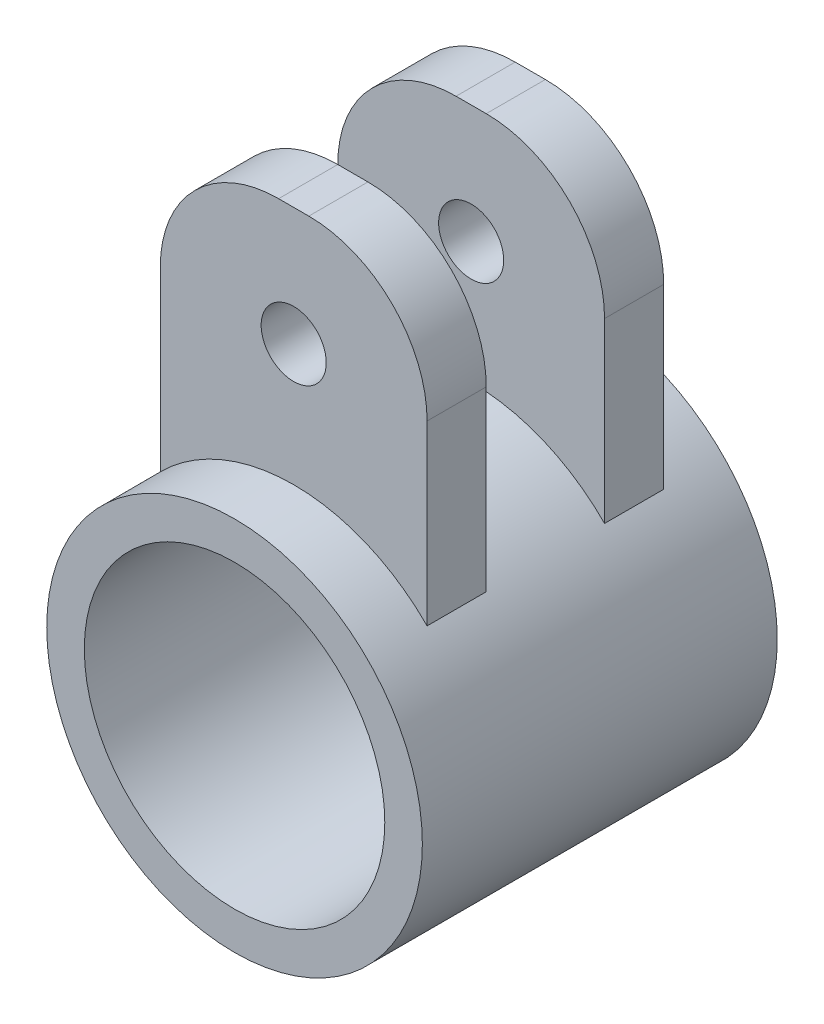
from build123d import *

# Parameters (mm, degrees)
SKETCH1_R            = 15.875
SKETCH1_R_2          = 12.7
BOSS_EXTRUDE1_DEPTH  = 15
BOSS_EXTRUDE2_DEPTH  = 10
CUT_EXTRUDE1_DEPTH   = 5
M5_CLEARANCE_HOLE1_D = 5.5


with BuildPart() as part:
    # Sketch1 → Boss-Extrude1 (new, symmetric)
    with BuildSketch(Plane.XY):
        Circle(SKETCH1_R)
        Circle(SKETCH1_R_2, mode=Mode.SUBTRACT)
    extrude(amount=BOSS_EXTRUDE1_DEPTH, both=True)

    # Sketch3 → Boss-Extrude2 (add, symmetric)
    with BuildSketch(Plane.XY):
        with BuildLine():
            Line((-11.276400848, 11.174005948), (-11.276400848, 26.174005948))
            ThreePointArc((-11.276400848, 26.174005948), (-8.34746866, 33.245073759), (-1.276400848, 36.174005948))
            Line((-1.276400848, 36.174005948), (1.276400848, 36.174005948))
            ThreePointArc((1.276400848, 36.174005948), (8.34746866, 33.245073759), (11.276400848, 26.174005948))
            Line((11.276400848, 26.174005948), (11.276400848, 11.174005948))
            ThreePointArc((11.276400848, 11.174005948), (0, 15.875), (-11.276400848, 11.174005948))
        make_face()
    extrude(amount=BOSS_EXTRUDE2_DEPTH, both=True)

    # Sketch3_2 → Cut-Extrude1 (cut, symmetric)
    with BuildSketch(Plane.XY):
        with BuildLine():
            Line((-11.276400848, 11.174005948), (-11.276400848, 26.174005948))
            ThreePointArc((-11.276400848, 26.174005948), (-8.34746866, 33.245073759), (-1.276400848, 36.174005948))
            Line((-1.276400848, 36.174005948), (1.276400848, 36.174005948))
            ThreePointArc((1.276400848, 36.174005948), (8.34746866, 33.245073759), (11.276400848, 26.174005948))
            Line((11.276400848, 26.174005948), (11.276400848, 11.174005948))
            ThreePointArc((11.276400848, 11.174005948), (0, 15.875), (-11.276400848, 11.174005948))
        make_face()
    extrude(amount=CUT_EXTRUDE1_DEPTH, both=True, mode=Mode.SUBTRACT)

    # M5 Clearance Hole1 (through all)
    with Locations(Plane.XY.offset(10)):
        with Locations((0, 26.174005948)):
            Hole(M5_CLEARANCE_HOLE1_D / 2)


solid = part.part
